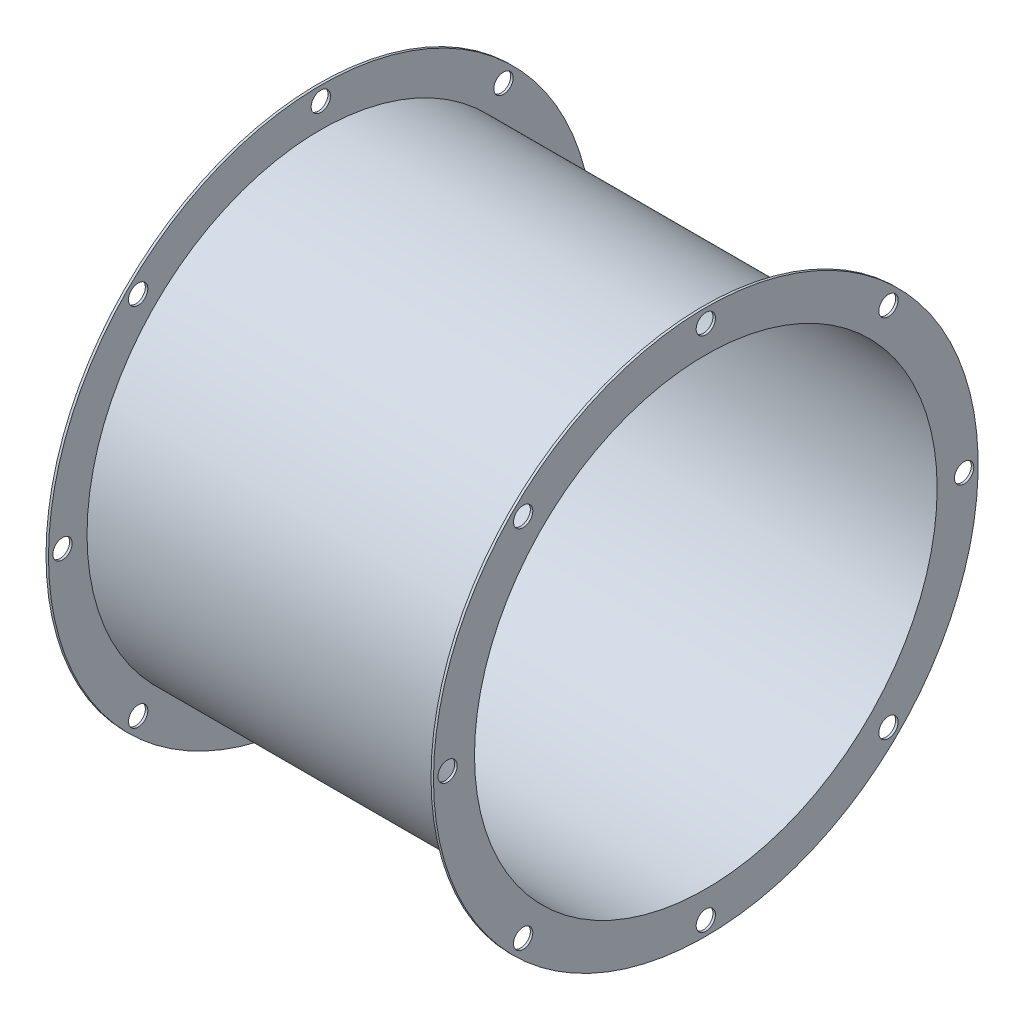
from build123d import *

# Parameters (mm, degrees)
SKETCH2_R          = 3.175
CUT_EXTRUDE1_DEPTH = 224.79
CIRPATTERN1_COUNT  = 8


with BuildPart() as part:
    # Sketch1 → Revolve1 (revolve)
    with BuildSketch(Plane.XY):
        Polygon((0, 76.2), (127.635, 76.2), (127.635, 89.7128), (126.8222, 89.7128), (126.8222, 77.0128), (0.8128, 77.0128), (0.8128, 89.7128), (0, 89.7128), align=None)
    revolve(axis=Axis((0, 0, 0), (1, 0, 0)))

    # Sketch2 → Cut-Extrude1 (cut)
    with BuildSketch(Plane(origin=(0, 0, 0), x_dir=(0, 0, -1), z_dir=(1, 0, 0))):
        with Locations((0, 85.09)):
            Circle(SKETCH2_R)
    cut_extrude1 = extrude(amount=CUT_EXTRUDE1_DEPTH, mode=Mode.SUBTRACT)

    # CirPattern1: Cut-Extrude1 ×8 about axis
    cirpattern1_axis = Axis((0, 0, 0), (1, 0, 0))
    for i in range(1, CIRPATTERN1_COUNT):
        add(cut_extrude1.rotate(cirpattern1_axis, i * 360 / CIRPATTERN1_COUNT), mode=Mode.SUBTRACT)


solid = part.part
